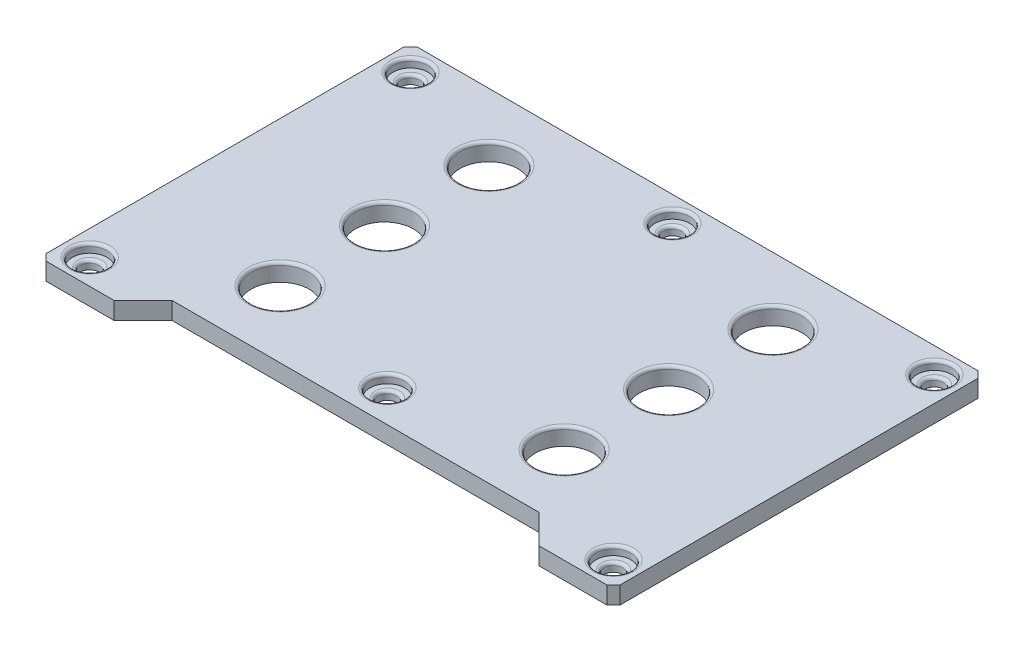
from build123d import *

# Parameters (mm, degrees)
SKETCH3_R           = 1.6
SKETCH3_R_2         = 5
BOSS_EXTRUDE1_DEPTH = 3
SKETCH4_R           = 3
CUT_EXTRUDE1_DEPTH  = 1.5
FILLET1_R           = 0.5


with BuildPart() as part:
    # Sketch3 → Boss-Extrude1 (new body)
    with BuildSketch(Plane(origin=(0, 0, 0), x_dir=(1, 0, 0), z_dir=(0, 1, 0))):
        Polygon((17.352282825, -19.043486229), (29.109642138, -19.043486229), (30.230962482, -17.922165885), (30.230962482, 43.835193428), (29.109642138, 44.956513771), (-67.647717175, 44.956513771), (-68.769037518, 43.835193428), (-68.769037518, -17.922165885), (-67.647717175, -19.043486229), (-55.890357862, -19.043486229), (-50.890357862, -14.043486229), (12.352282825, -14.043486229), align=None)
        with Locations((-64.439037518, 40.626513771)):
            Circle(SKETCH3_R, mode=Mode.SUBTRACT)
        with Locations((-64.439037518, -14.713486229)):
            Circle(SKETCH3_R, mode=Mode.SUBTRACT)
        with Locations((25.900962482, 40.626513771)):
            Circle(SKETCH3_R, mode=Mode.SUBTRACT)
        with Locations((25.900962482, -14.713486229)):
            Circle(SKETCH3_R, mode=Mode.SUBTRACT)
        with Locations((-43.769037518, 33.456513771)):
            Circle(SKETCH3_R_2, mode=Mode.SUBTRACT)
        with Locations((-43.769037518, 15.456513771)):
            Circle(SKETCH3_R_2, mode=Mode.SUBTRACT)
        with Locations((-43.769037518, -2.543486229)):
            Circle(SKETCH3_R_2, mode=Mode.SUBTRACT)
        with Locations((5.230962482, -2.543486229)):
            Circle(SKETCH3_R_2, mode=Mode.SUBTRACT)
        with Locations((5.230962482, 15.456513771)):
            Circle(SKETCH3_R_2, mode=Mode.SUBTRACT)
        with Locations((5.230962482, 33.456513771)):
            Circle(SKETCH3_R_2, mode=Mode.SUBTRACT)
        with Locations((-19.269037518, 40.626513771)):
            Circle(SKETCH3_R, mode=Mode.SUBTRACT)
        with Locations((-19.269037518, -8.543486229)):
            Circle(SKETCH3_R, mode=Mode.SUBTRACT)
    extrude(amount=-BOSS_EXTRUDE1_DEPTH)

    # Sketch4 → Cut-Extrude1 (cut)
    with BuildSketch(Plane(origin=(0, 0, 0), x_dir=(1, 0, 0), z_dir=(0, 1, 0))):
        with Locations((-64.439037518, 40.626513771)):
            Circle(SKETCH4_R)
        with Locations((-64.439037518, -14.713486229)):
            Circle(SKETCH4_R)
        with Locations((25.900962482, 40.626513771)):
            Circle(SKETCH4_R)
        with Locations((25.900962482, -14.713486229)):
            Circle(SKETCH4_R)
        with Locations((-19.269037518, 40.626513771)):
            Circle(SKETCH4_R)
        with Locations((-19.269037518, -8.543486229)):
            Circle(SKETCH4_R)
    extrude(amount=-CUT_EXTRUDE1_DEPTH, mode=Mode.SUBTRACT)

    # Fillet1
    fillet1_edges = [part.edges().sort_by_distance(p)[0] for p in [
        (-67.439037518, 0, 14.713486229),
        (-66.039037518, -1.5, 14.713486229),
        (-22.269037518, 0, 8.543486229),
        (-20.869037518, -1.5, 8.543486229),
        (-67.439037518, 0, -40.626513771),
        (-66.039037518, -1.5, -40.626513771),
        (-48.769037518, 0, -33.456513771),
        (-48.769037518, 0, -15.456513771),
        (-48.769037518, 0, 2.543486229),
        (0.230962482, 0, 2.543486229),
        (0.230962482, 0, -15.456513771),
        (0.230962482, 0, -33.456513771),
        (-22.269037518, 0, -40.626513771),
        (-20.869037518, -1.5, -40.626513771),
        (22.900962482, 0, 14.713486229),
        (24.300962482, -1.5, 14.713486229),
        (22.900962482, 0, -40.626513771),
        (24.300962482, -1.5, -40.626513771),
    ]]
    fillet(fillet1_edges, radius=FILLET1_R)


solid = part.part
